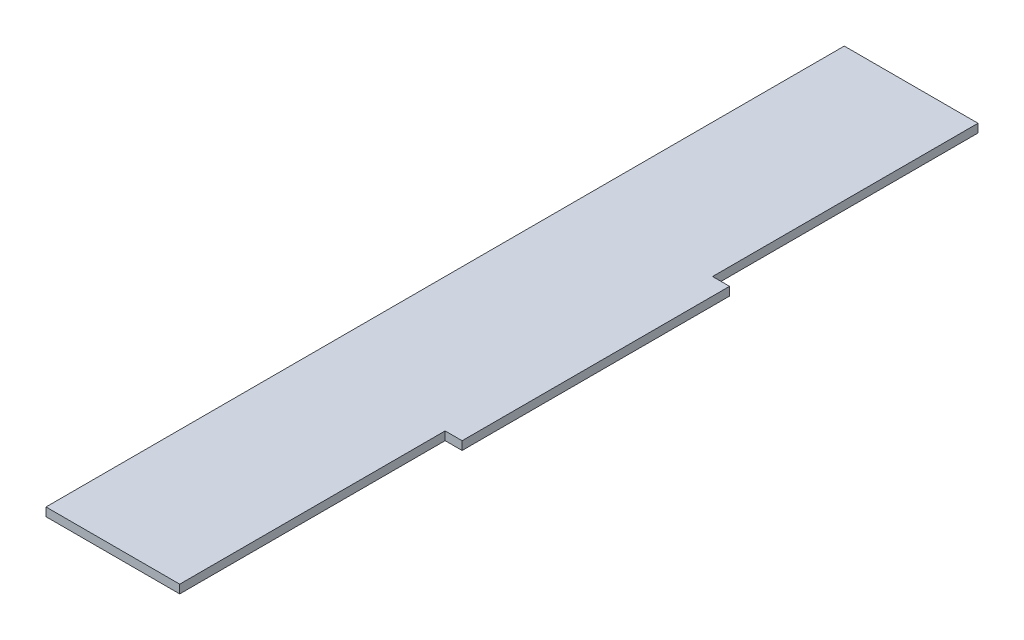
from build123d import *

# Parameters (mm, degrees)
BOSS_EXTRUDE1_DEPTH = 3.175


with BuildPart() as part:
    # Sketch1 → Boss-Extrude1 (new body)
    with BuildSketch(Plane(origin=(0, 0, 0), x_dir=(1, 0, 0), z_dir=(0, 1, 0))):
        Polygon((-25, 0), (-25, 99.25), (25, 99.25), (25, 0), (31.35, 0), (31.35, -100), (25, -100), (25, -199.25), (-25, -199.25), (-25, -100), align=None)
    extrude(amount=BOSS_EXTRUDE1_DEPTH)


solid = part.part
